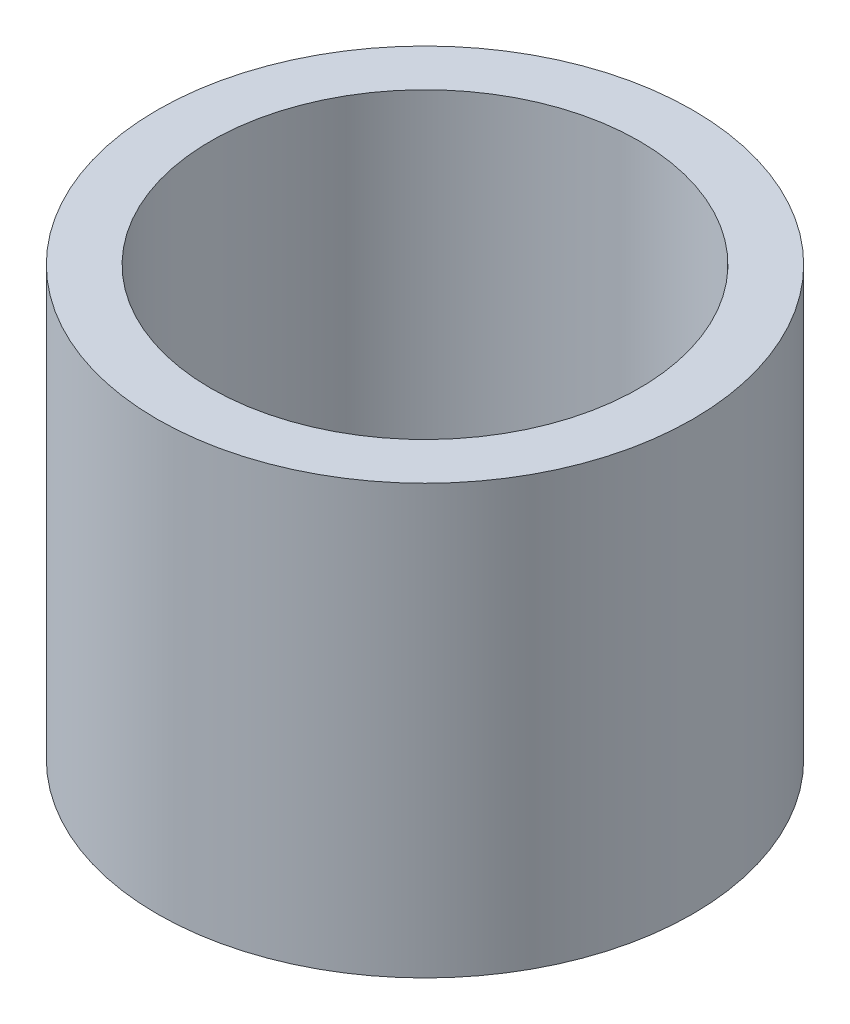
from build123d import *

# Parameters (mm, degrees)
CROQUIS1_R              = 7.5
CROQUIS1_R_2            = 6
SALIENTE_EXTRUIR1_DEPTH = 12
ESCALA1_SCALE           = 7


with BuildPart() as part:
    # Croquis1 → Saliente-Extruir1 (new body)
    with BuildSketch(Plane(origin=(0, 0, 0), x_dir=(1, 0, 0), z_dir=(0, 1, 0))):
        Circle(CROQUIS1_R)
        Circle(CROQUIS1_R_2, mode=Mode.SUBTRACT)
    extrude(amount=SALIENTE_EXTRUIR1_DEPTH)


with BuildPart() as part_1:
    # Escala1: scaled about (0, 6, 0)
    add(part.part.scale(ESCALA1_SCALE).moved(Location((0, -36, 0))))


solid = part_1.part
